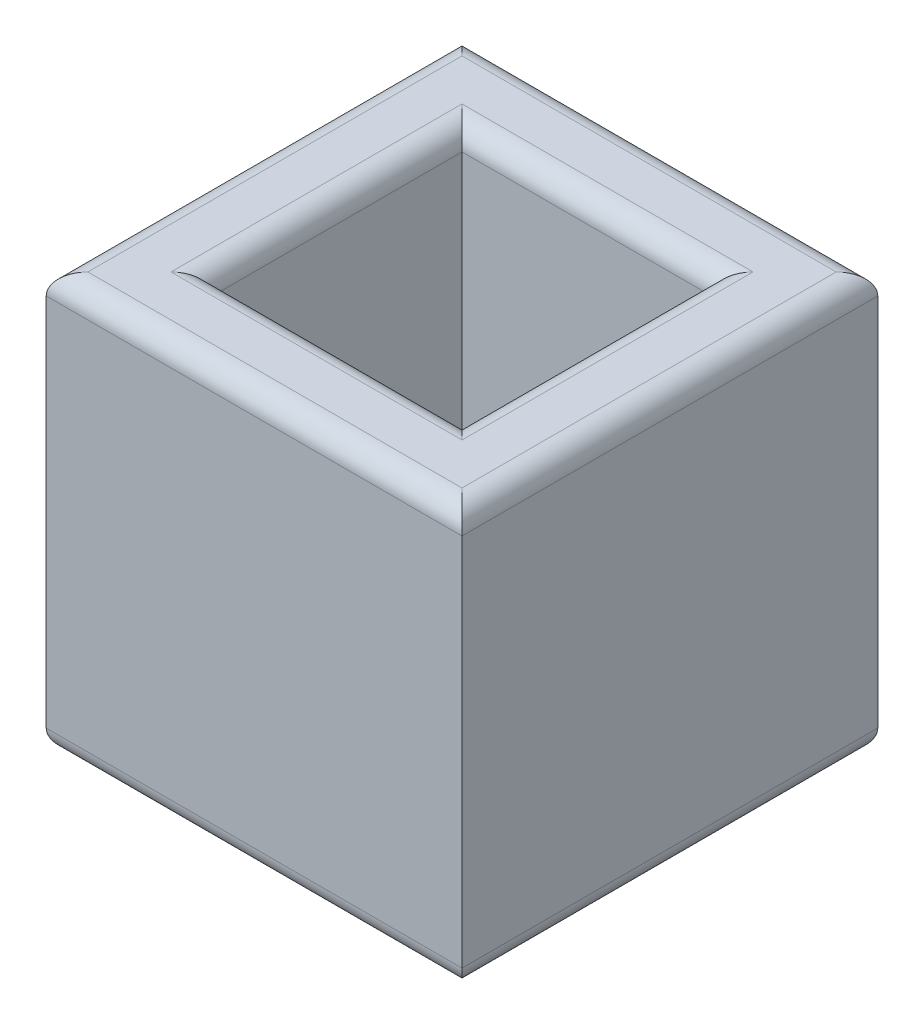
from build123d import *

# Parameters (mm, degrees)
SKETCH1_W               = 127
SKETCH1_H               = 127
BOSS_EXTRUDE1_DEPTH     = 127
SKETCH2_W               = 76.2
SKETCH2_H               = 76.2
CUT_EXTRUDE1_DEPTH      = 1
CUT_EXTRUDE1_DEPTH_BACK = 128
FILLET3_R               = 6.35


with BuildPart() as part:
    # Sketch1 → Boss-Extrude1 (new body)
    with BuildSketch(Plane(origin=(0, 0, 0), x_dir=(1, 0, 0), z_dir=(0, 1, 0))):
        Rectangle(SKETCH1_W, SKETCH1_H)
    extrude(amount=BOSS_EXTRUDE1_DEPTH)

    # Sketch2 → Cut-Extrude1 (cut, two sides)
    with BuildSketch(Plane(origin=(0, 127, 0), x_dir=(1, 0, 0), z_dir=(0, 1, 0))) as cut_extrude1_sk:
        Rectangle(SKETCH2_W, SKETCH2_H)
    extrude(amount=CUT_EXTRUDE1_DEPTH, mode=Mode.SUBTRACT)
    extrude(cut_extrude1_sk.sketch, amount=-CUT_EXTRUDE1_DEPTH_BACK, mode=Mode.SUBTRACT)

    # Fillet3
    fillet3_edges = [part.edges().sort_by_distance(p)[0] for p in [
        (63.5, 127, 0),
        (0, 127, 63.5),
        (38.1, 127, 0),
        (38.1, 0, 0),
        (0, 127, 38.1),
        (0, 0, 38.1),
        (-38.1, 127, 0),
        (-38.1, 0, 0),
        (0, 127, -38.1),
        (0, 0, -38.1),
        (-63.5, 127, 0),
        (0, 0, 63.5),
        (63.5, 0, 0),
        (0, 0, -63.5),
        (-63.5, 0, 0),
        (0, 127, -63.5),
    ]]
    fillet(fillet3_edges, radius=FILLET3_R)


solid = part.part
